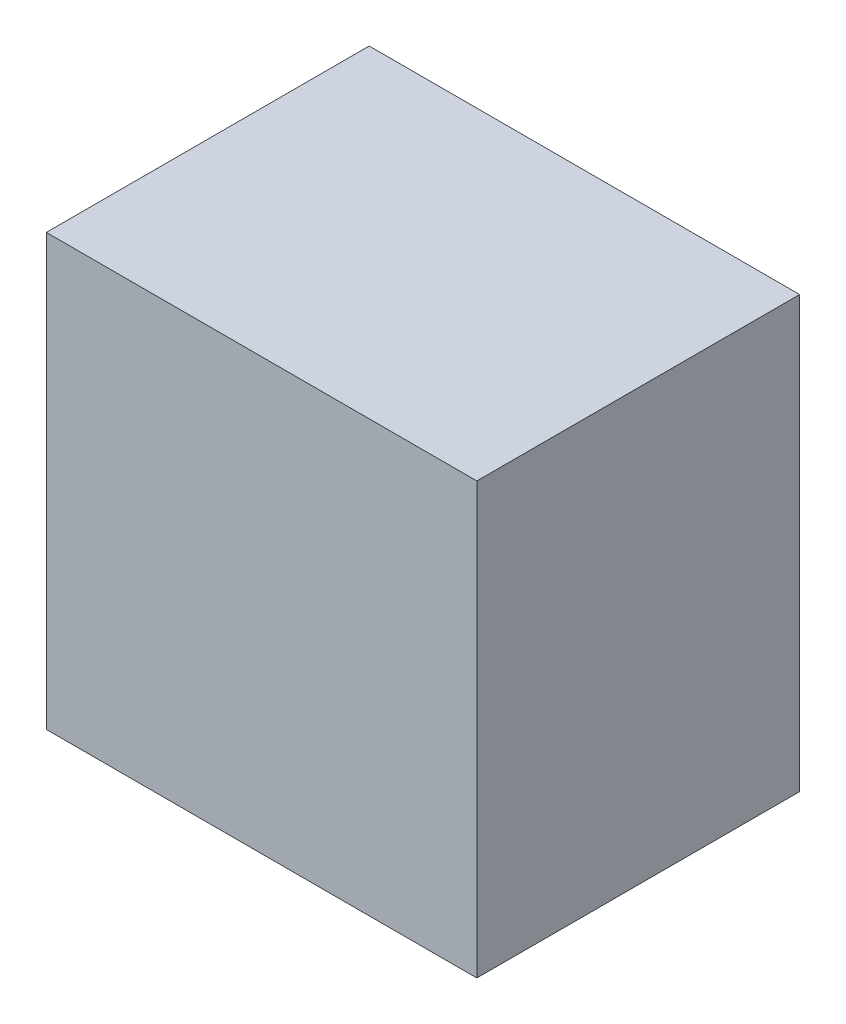
from build123d import *

# Parameters (mm, degrees)
SKETCH1_W           = 25.4
SKETCH1_H           = 19.05
BOSS_EXTRUDE1_DEPTH = 25.4


with BuildPart() as part:
    # Sketch1 → Boss-Extrude1 (new body)
    with BuildSketch(Plane(origin=(0, 0, 0), x_dir=(1, 0, 0), z_dir=(0, 1, 0))):
        with Locations((12.7, 9.525)):
            Rectangle(SKETCH1_W, SKETCH1_H)
    extrude(amount=BOSS_EXTRUDE1_DEPTH)


solid = part.part
